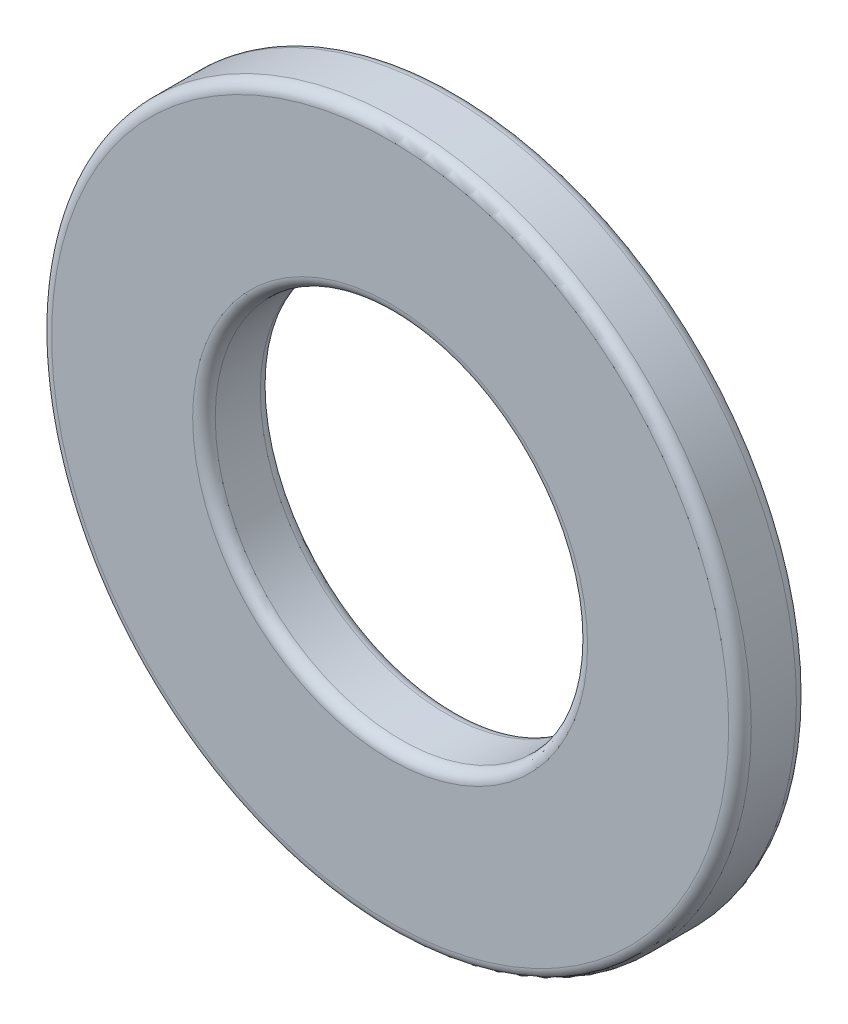
from build123d import *

# Parameters (mm, degrees)
SKETCH1_R           = 7.75
SKETCH1_R_2         = 4.125
BOSS_EXTRUDE1_DEPTH = 1.5
FILLET1_R           = 0.25


with BuildPart() as part:
    # Sketch1 → Boss-Extrude1 (new body)
    with BuildSketch(Plane.XY):
        Circle(SKETCH1_R)
        Circle(SKETCH1_R_2, mode=Mode.SUBTRACT)
    extrude(amount=BOSS_EXTRUDE1_DEPTH)

    # Fillet1
    fillet1_edges = [part.edges().sort_by_distance(p)[0] for p in [
        (-7.75, 0, 0),
        (-7.75, 0, 1.5),
        (-4.125, 0, 0),
        (-4.125, 0, 1.5),
    ]]
    fillet(fillet1_edges, radius=FILLET1_R)


solid = part.part
